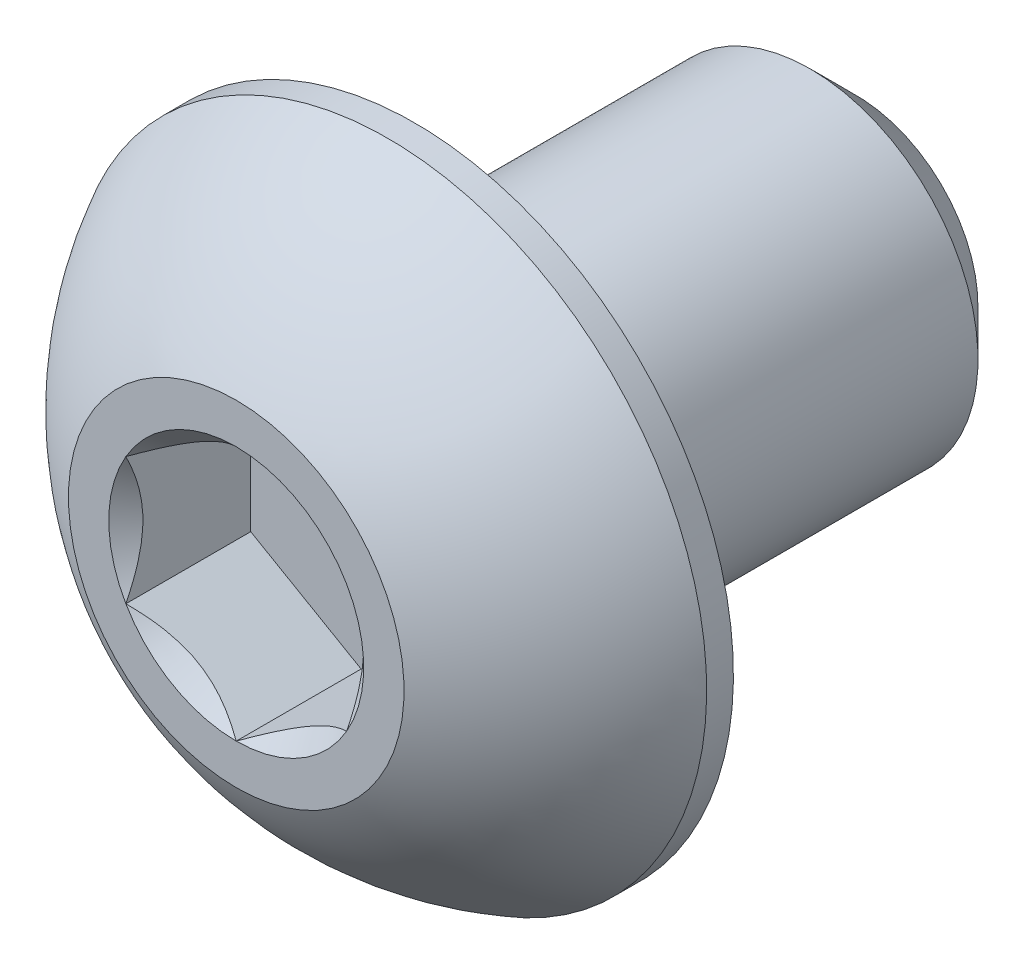
from build123d import *

# Parameters (mm, degrees)
SKETCH11_W         = 6.35
SKETCH11_H         = 2.413
CHAMFER1_SIZE      = 0.661458333
CUT_EXTRUDE2_DEPTH = 1.79578
SKETCH6_R          = 1.833087105
CUT_EXTRUDE3_DEPTH = 1.79578
CUT_EXTRUDE3_TAPER = 45


with BuildPart() as part:
    # Sketch11 → Revolve1 (revolve)
    with BuildSketch(Plane(origin=(0, 0, 0), x_dir=(0, 0, -1), z_dir=(1, 0, 0))):
        with Locations((1.2827, 1.2065)):
            Rectangle(SKETCH11_W, SKETCH11_H)
    revolve(axis=Axis((0, 0, 1.8923), (0, 0, -1)))

    # Chamfer1
    chamfer1_edges = [part.edges().sort_by_distance(p)[0] for p in [
        (0, -2.413, -4.4577),
    ]]
    chamfer(chamfer1_edges, length=CHAMFER1_SIZE)


with BuildPart() as body_2:
    # Sketch7 → Revolve2 (revolve)
    with BuildSketch(Plane(origin=(0, 0, 0), x_dir=(0, 0, -1), z_dir=(1, 0, 0))):
        with BuildLine():
            Line((-2.27711, 4.5847), (-1.8923, 4.5847))
            Line((-1.8923, 4.5847), (-1.8923, 0))
            Line((-1.8923, 0), (-4.4577, 0))
            Line((-4.4577, 0), (-4.4577, 2.413))
            ThreePointArc((-4.4577, 2.413), (-3.532669674, 3.664791196), (-2.27711, 4.5847))
        make_face()
    revolve(axis=Axis((0, 0, 4.4577), (0, 0, -1)))

    # Sketch5 → Cut-Extrude2 (cut)
    with BuildSketch(Plane.XY.offset(4.4577)):
        Polygon((1.5875, -0.916543552), (1.5875, 0.916543552), (0, 1.833087105), (-1.5875, 0.916543552), (-1.5875, -0.916543552), (0, -1.833087105), align=None)
    extrude(amount=-CUT_EXTRUDE2_DEPTH, mode=Mode.SUBTRACT)

    # Sketch6 → Cut-Extrude3 (cut)
    with BuildSketch(Plane.XY.offset(4.4577)):
        Circle(SKETCH6_R)
    extrude(amount=-CUT_EXTRUDE3_DEPTH, taper=CUT_EXTRUDE3_TAPER, mode=Mode.SUBTRACT)


solid = Compound([part.part, body_2.part])
